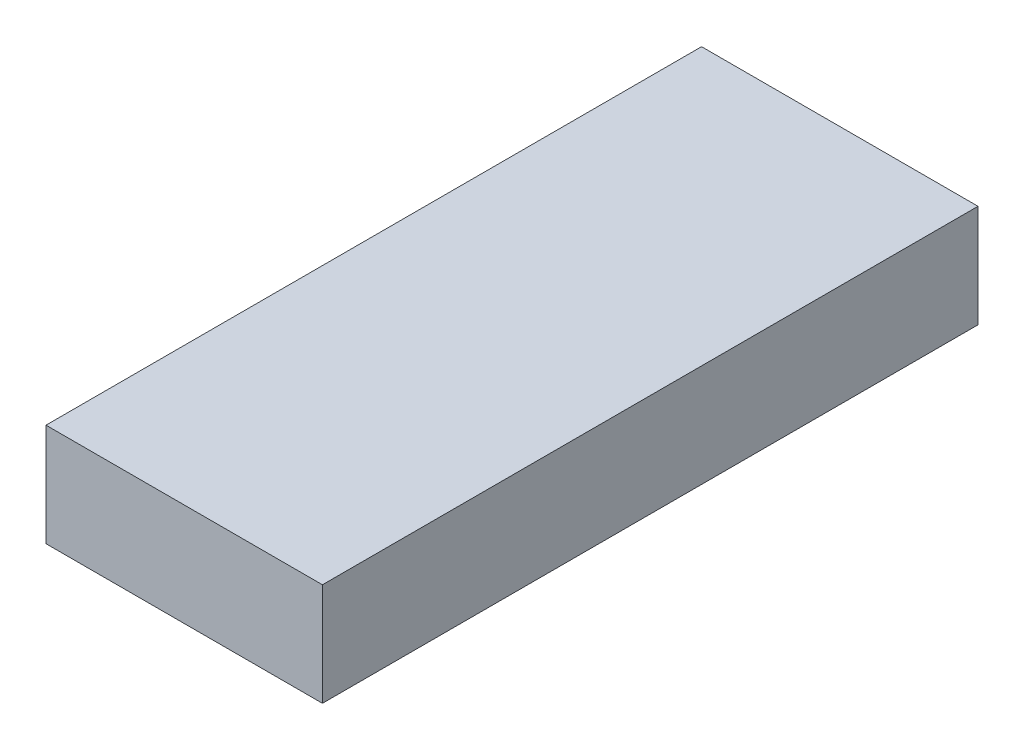
from build123d import *

# Parameters (mm, degrees)
SKETCH_1_W      = 35
SKETCH_1_H      = 13
EXTRUDE_1_DEPTH = 83


with BuildPart() as part:
    # ｽｹｯﾁ1 → ﾎﾞｽ - 押し出し1 (new body)
    with BuildSketch(Plane.XY):
        with Locations((5.604004653, -2.496462264)):
            Rectangle(SKETCH_1_W, SKETCH_1_H)
    extrude(amount=EXTRUDE_1_DEPTH)


solid = part.part
